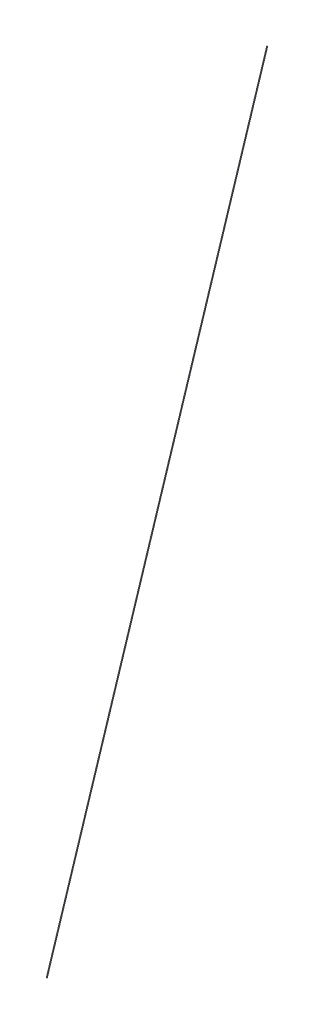
from build123d import *

# Parameters (mm, degrees)
SWEEP_1_PROFILE_R = 0.5


with BuildPart() as part:
    # 扫描1: sweep along a path in 草图3
    with BuildLine(Plane.XY) as sweep_1_path:
        Line((0, 0), (307.5, 1279.38))
    # 扫描1 profile (on start of the path) → 扫描1 (sweep)
    with BuildSketch(Plane(origin=(0, 0, 0), x_dir=(0.972309847, -0.233695445, 0), z_dir=(0.233695445, 0.972309847, 0))):
        Circle(SWEEP_1_PROFILE_R)
    sweep(path=sweep_1_path.line)


solid = part.part
